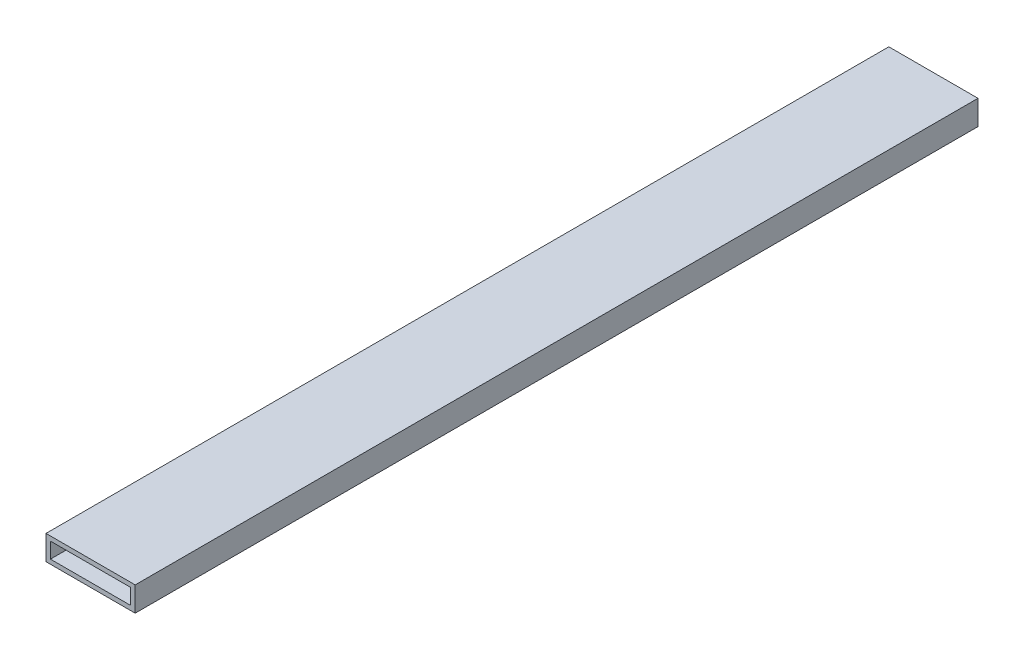
from build123d import *

# Parameters (mm, degrees)
SKETCH1_W           = 40
SKETCH1_H           = 11
SKETCH1_W_2         = 36
SKETCH1_H_2         = 7
BOSS_EXTRUDE1_DEPTH = 378


with BuildPart() as part:
    # Sketch1 → Boss-Extrude1 (new body)
    with BuildSketch(Plane.XY):
        Rectangle(SKETCH1_W, SKETCH1_H)
        Rectangle(SKETCH1_W_2, SKETCH1_H_2, mode=Mode.SUBTRACT)
    extrude(amount=BOSS_EXTRUDE1_DEPTH)


solid = part.part
